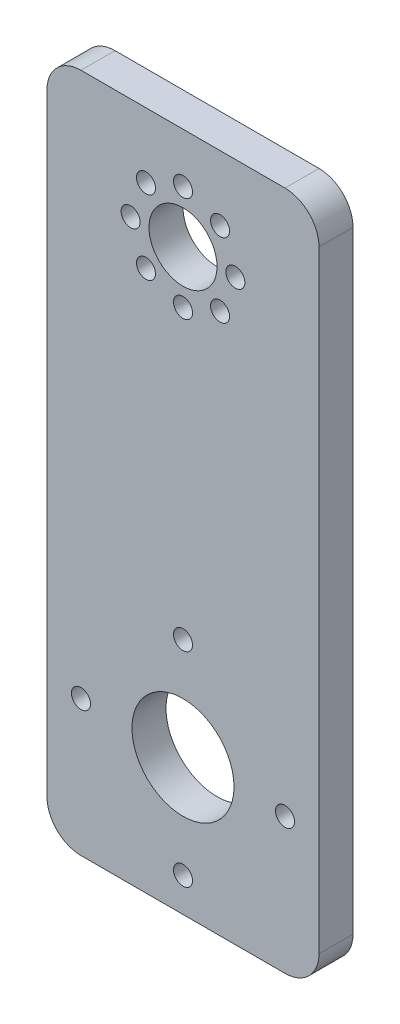
from build123d import *

# Parameters (mm, degrees)
SKETCH1_W           = 50.8
SKETCH1_H           = 127
SKETCH1_R           = 9.525
SKETCH1_R_2         = 6.35
BOSS_EXTRUDE1_DEPTH = 6.35
SKETCH2_R           = 1.778
CUT_EXTRUDE1_DEPTH  = 6.35
CIRPATTERN1_COUNT   = 4
SKETCH3_R           = 1.778
CUT_EXTRUDE2_DEPTH  = 6.35
CIRPATTERN2_COUNT   = 8
FILLET1_R           = 6.35


with BuildPart() as part:
    # Sketch1 → Boss-Extrude1 (new body)
    with BuildSketch(Plane.XY):
        with Locations((25.4, 63.5)):
            Rectangle(SKETCH1_W, SKETCH1_H)
        with Locations((25.4, 25.4)):
            Circle(SKETCH1_R, mode=Mode.SUBTRACT)
        with Locations((25.4, 107.95)):
            Circle(SKETCH1_R_2, mode=Mode.SUBTRACT)
    extrude(amount=BOSS_EXTRUDE1_DEPTH)

    # Sketch2 → Cut-Extrude1 (cut)
    with BuildSketch(Plane.XY.offset(6.35)):
        with Locations((25.4, 44.45)):
            Circle(SKETCH2_R)
    cut_extrude1 = extrude(amount=-CUT_EXTRUDE1_DEPTH, mode=Mode.SUBTRACT)

    # CirPattern1: Cut-Extrude1 ×4 about axis
    cirpattern1_axis = Axis((25.4, 25.4, 0), (0, 0, 1))
    for i in range(1, CIRPATTERN1_COUNT):
        add(cut_extrude1.rotate(cirpattern1_axis, i * 360 / CIRPATTERN1_COUNT), mode=Mode.SUBTRACT)

    # Sketch3 → Cut-Extrude2 (cut)
    with BuildSketch(Plane.XY.offset(6.35)):
        with Locations((25.4, 117.729)):
            Circle(SKETCH3_R)
    cut_extrude2 = extrude(amount=-CUT_EXTRUDE2_DEPTH, mode=Mode.SUBTRACT)

    # CirPattern2: Cut-Extrude2 ×8 about axis
    cirpattern2_axis = Axis((25.4, 107.95, 0), (0, 0, 1))
    for i in range(1, CIRPATTERN2_COUNT):
        add(cut_extrude2.rotate(cirpattern2_axis, i * 360 / CIRPATTERN2_COUNT), mode=Mode.SUBTRACT)

    # Fillet1
    fillet1_edges = [part.edges().sort_by_distance(p)[0] for p in [
        (0, 127, 3.175),
        (50.8, 127, 3.175),
        (50.8, 0, 3.175),
        (0, 0, 3.175),
    ]]
    fillet(fillet1_edges, radius=FILLET1_R)


solid = part.part
